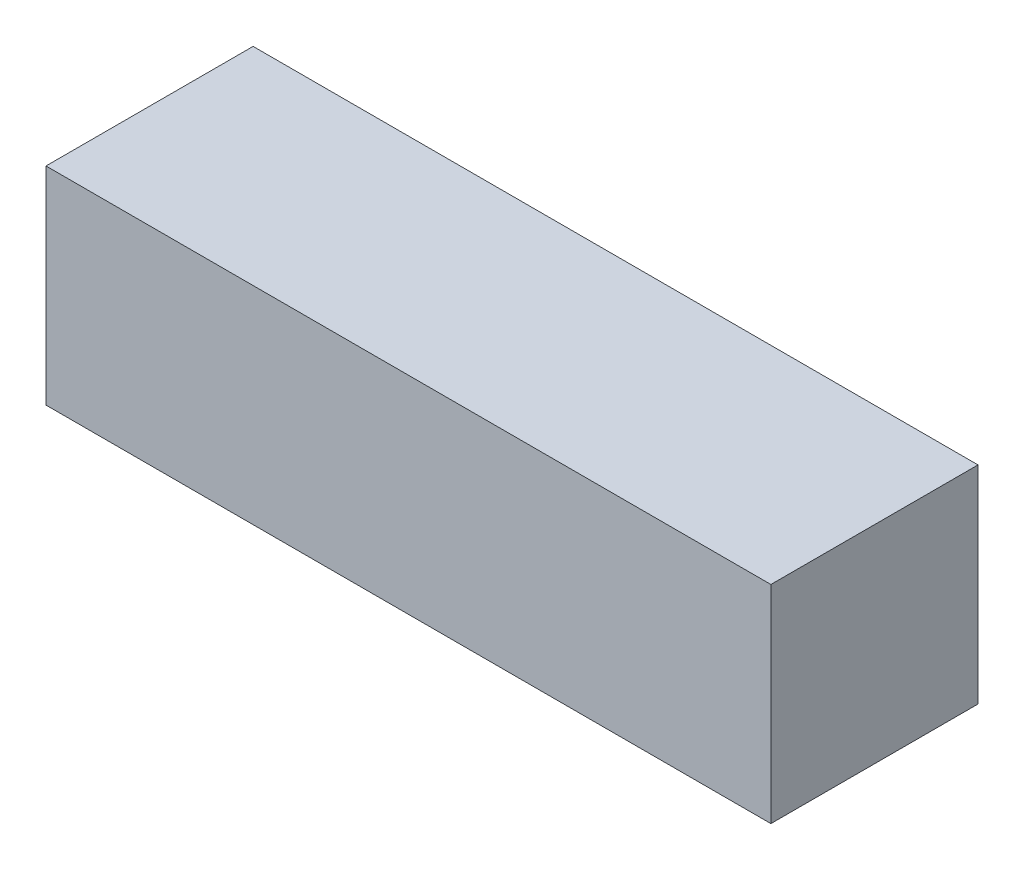
from build123d import *

# Parameters (mm, degrees)
SKETCH_1_W      = 10
SKETCH_1_H      = 10
EXTRUDE_1_DEPTH = 35


with BuildPart() as part:
    # Эскиз1 → Бобышка-Вытянуть1 (new body)
    with BuildSketch(Plane(origin=(0, 0, 0), x_dir=(0, 0, -1), z_dir=(1, 0, 0))):
        with Locations((5, 5)):
            Rectangle(SKETCH_1_W, SKETCH_1_H)
    extrude(amount=EXTRUDE_1_DEPTH)


solid = part.part
